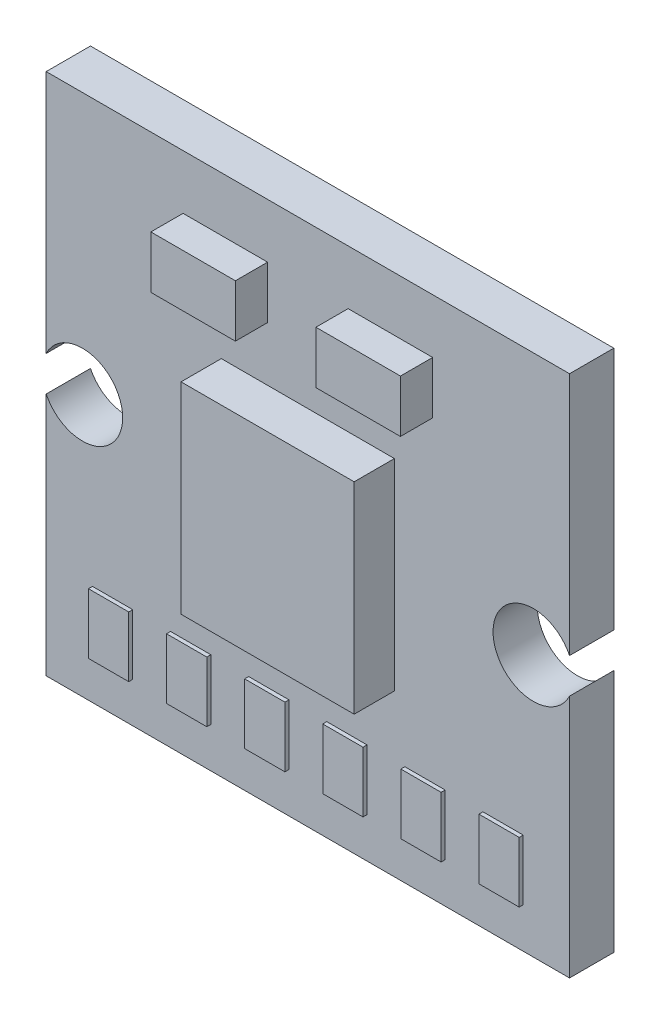
from build123d import *

# Parameters (mm, degrees)
SKETCH_1_W          = 13
SKETCH_1_H          = 13
EXTRUDE_1_DEPTH     = 1.1
SKETCH_2_W          = 4.3
SKETCH_2_H          = 5
EXTRUDE_2_DEPTH     = 1
SKETCH_3_W          = 2.1
SKETCH_3_H          = 1.3
EXTRUDE_3_DEPTH     = 0.8
SKETCH_4_W          = 1
SKETCH_4_H          = 1.5
EXTRUDE_4_DEPTH     = 0.1
SKETCH_5_R          = 1
CUT_EXTRUDE_1_DEPTH = 1.1


with BuildPart() as part:
    # 스케치1 → 보스-돌출1 (new body)
    with BuildSketch(Plane.XY):
        Rectangle(SKETCH_1_W, SKETCH_1_H)
    extrude(amount=EXTRUDE_1_DEPTH)

    # 스케치2 → 보스-돌출2 (add)
    with BuildSketch(Plane.XY.offset(1.1)):
        Rectangle(SKETCH_2_W, SKETCH_2_H)
    extrude(amount=EXTRUDE_2_DEPTH)

    # 스케치3 → 보스-돌출3 (add)
    with BuildSketch(Plane.XY.offset(1.1)):
        with Locations((-2.05, 4.5)):
            Rectangle(SKETCH_3_W, SKETCH_3_H)
        with Locations((2.05, 4.5)):
            Rectangle(SKETCH_3_W, SKETCH_3_H)
    extrude(amount=EXTRUDE_3_DEPTH)

    # 스케치4 → 보스-돌출4 (add)
    with BuildSketch(Plane.XY.offset(1.1)):
        with Locations((-2.91, -4.75)):
            Rectangle(SKETCH_4_W, SKETCH_4_H)
        with Locations((4.85, -4.75)):
            Rectangle(SKETCH_4_W, SKETCH_4_H)
        with Locations((-4.85, -4.75)):
            Rectangle(SKETCH_4_W, SKETCH_4_H)
        with Locations((-0.97, -4.75)):
            Rectangle(SKETCH_4_W, SKETCH_4_H)
        with Locations((0.97, -4.75)):
            Rectangle(SKETCH_4_W, SKETCH_4_H)
        with Locations((2.91, -4.75)):
            Rectangle(SKETCH_4_W, SKETCH_4_H)
    extrude(amount=EXTRUDE_4_DEPTH)

    # 스케치5 → 컷-돌출1 (cut)
    with BuildSketch(Plane.XY.offset(1.1)):
        with Locations((5.6, 0)):
            Circle(SKETCH_5_R)
        with Locations((-5.6, 0)):
            Circle(SKETCH_5_R)
    extrude(amount=-CUT_EXTRUDE_1_DEPTH, mode=Mode.SUBTRACT)


solid = part.part
